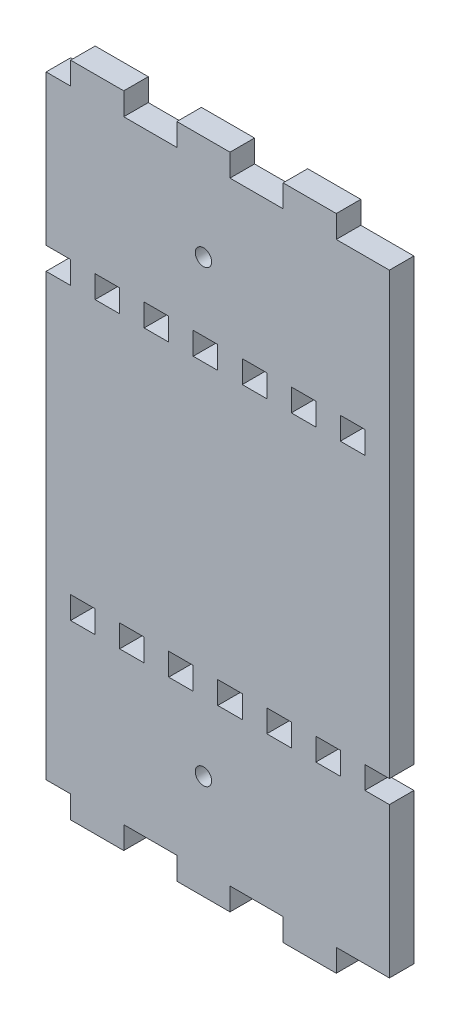
from build123d import *

# Parameters (mm, degrees)
MODEL_R             = 2
MODEL_W             = 6
MODEL_H             = 5.5
BOSS_EXTRUDE1_DEPTH = 6


with BuildPart() as part:
    # Model → Boss-Extrude1 (new body)
    with BuildSketch(Plane.XY):
        Polygon((-665.309655483, 302.874496351), (-665.309655483, 339.624496351), (-671.309655483, 339.624496351), (-671.309655483, 345.124496351), (-665.309655483, 345.124496351), (-665.309655483, 452.874496351), (-678.309655483, 452.874496351), (-678.309655483, 458.373843725), (-691.308294267, 458.372538473), (-691.309655483, 452.874496351), (-704.308294267, 452.874496351), (-704.308294267, 458.372538473), (-717.306933052, 458.37123322), (-717.308294267, 452.874496351), (-730.306933052, 452.874496351), (-730.306933052, 458.37123322), (-743.305571836, 458.369927968), (-743.305020076, 452.875099304), (-749.309655483, 452.874496351), (-749.309655483, 416.124496351), (-743.309655483, 416.124496351), (-743.309655483, 410.624496351), (-749.309655483, 410.624496351), (-749.309655483, 302.874496351), (-743.305020081, 302.874496351), (-743.305571836, 297.379717361), (-730.306933052, 297.378412108), (-730.306933052, 302.878412108), (-717.308294267, 302.877106856), (-717.306933052, 297.378412108), (-704.308294267, 297.377106856), (-704.308294267, 302.877106856), (-691.309655483, 302.875801604), (-691.308294267, 297.377106856), (-678.309655483, 297.375801604), (-678.309655483, 302.875801604), align=None)
        with Locations((-710.804492218, 322.87645388)):
            Circle(MODEL_R, mode=Mode.SUBTRACT)
        with Locations((-710.804492218, 432.873034264)):
            Circle(MODEL_R, mode=Mode.SUBTRACT)
        with Locations((-698.309655483, 413.374496351)):
            Rectangle(MODEL_W, MODEL_H, mode=Mode.SUBTRACT)
        with Locations((-686.309655483, 413.374496351)):
            Rectangle(MODEL_W, MODEL_H, mode=Mode.SUBTRACT)
        with Locations((-674.309655483, 413.374496351)):
            Rectangle(MODEL_W, MODEL_H, mode=Mode.SUBTRACT)
        with Locations((-710.309655483, 413.374496351)):
            Rectangle(MODEL_W, MODEL_H, mode=Mode.SUBTRACT)
        with Locations((-722.309655483, 413.374496351)):
            Rectangle(MODEL_W, MODEL_H, mode=Mode.SUBTRACT)
        with Locations((-734.309655483, 413.374496351)):
            Rectangle(MODEL_W, MODEL_H, mode=Mode.SUBTRACT)
        with Locations((-704.309655483, 342.374496351)):
            Rectangle(MODEL_W, MODEL_H, mode=Mode.SUBTRACT)
        with Locations((-692.309655483, 342.374496351)):
            Rectangle(MODEL_W, MODEL_H, mode=Mode.SUBTRACT)
        with Locations((-680.309655483, 342.374496351)):
            Rectangle(MODEL_W, MODEL_H, mode=Mode.SUBTRACT)
        with Locations((-716.309655483, 342.374496351)):
            Rectangle(MODEL_W, MODEL_H, mode=Mode.SUBTRACT)
        with Locations((-728.309655483, 342.374496351)):
            Rectangle(MODEL_W, MODEL_H, mode=Mode.SUBTRACT)
        with Locations((-740.309655483, 342.374496351)):
            Rectangle(MODEL_W, MODEL_H, mode=Mode.SUBTRACT)
    extrude(amount=BOSS_EXTRUDE1_DEPTH)


solid = part.part
